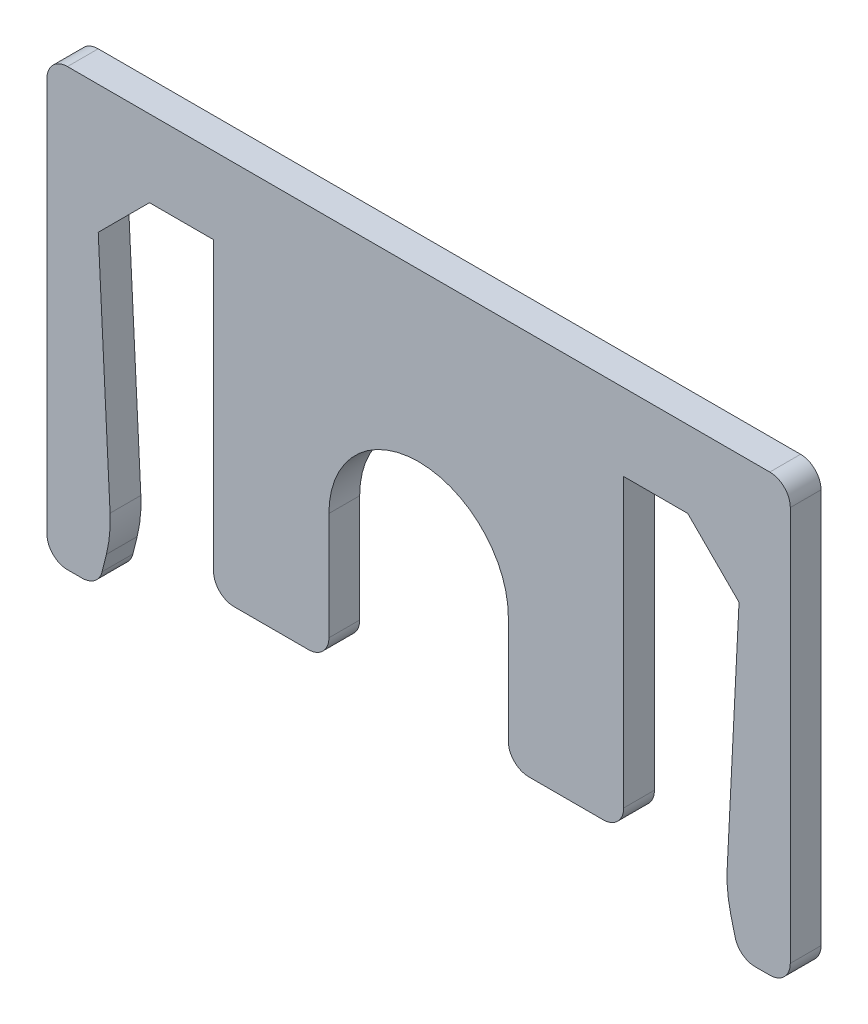
from build123d import *

# Parameters (mm, degrees)
BOSS_EXTRUDE1_DEPTH = 1.2
FILLET1_R           = 5
FILLET2_R           = 0.8


with BuildPart() as part:
    # Sketch1 → Boss-Extrude1 (new body)
    with BuildSketch(Plane.XY):
        with BuildLine():
            Line((-10.5, 0), (-12.5, -2))
            Line((-12.5, -2), (-12, -12))
            Line((-12, -12), (-12.5, -14))
            Line((-12.5, -14), (-14.5, -14))
            Line((-14.5, -14), (-14.5, 3))
            Line((-14.5, 3), (-12.5, 3))
            Line((-12.5, 3), (12.5, 3))
            Line((12.5, 3), (14.5, 3))
            Line((14.5, 3), (14.5, -14))
            Line((14.5, -14), (12.5, -14))
            Line((12.5, -14), (12, -12))
            Line((12, -12), (12.5, -2))
            Line((12.5, -2), (10.5, 0))
            Line((10.5, 0), (8, 0))
            Line((8, 0), (8, -12))
            Line((8, -12), (3.5, -12))
            Line((3.5, -12), (3.5, -7))
            ThreePointArc((3.5, -7), (0, -3.5), (-3.5, -7))
            Line((-3.5, -7), (-3.5, -12))
            Line((-3.5, -12), (-8, -12))
            Line((-8, -12), (-8, 0))
            Line((-8, 0), (-10.5, 0))
        make_face()
    extrude(amount=BOSS_EXTRUDE1_DEPTH)

    # Fillet1
    fillet1_edges = [part.edges().sort_by_distance(p)[0] for p in [
        (-12, -12, 0.6),
        (12, -12, 0.6),
    ]]
    fillet(fillet1_edges, radius=FILLET1_R)

    # Fillet2
    fillet2_edges = [part.edges().sort_by_distance(p)[0] for p in [
        (-12.5, -14, 0.6),
        (-14.5, -14, 0.6),
        (-14.5, 3, 0.6),
        (14.5, 3, 0.6),
        (14.5, -14, 0.6),
        (12.5, -14, 0.6),
        (8, -12, 0.6),
        (3.5, -12, 0.6),
        (-3.5, -12, 0.6),
        (-8, -12, 0.6),
    ]]
    fillet(fillet2_edges, radius=FILLET2_R)


solid = part.part
